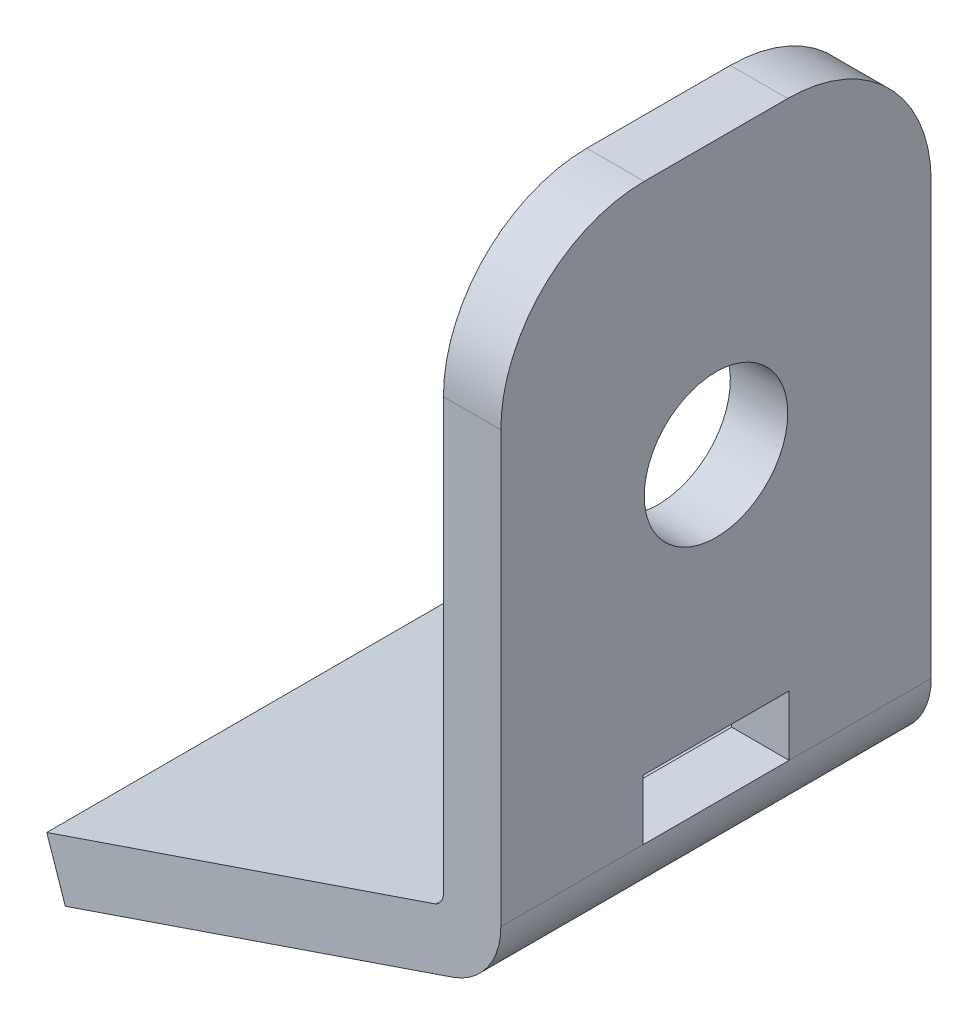
from build123d import *

# Parameters (mm, degrees)
DODANIE_WYCI_GNI_CIE1_DEPTH = 15
SZKIC2_R                    = 2.5
WYTNIJ_WYCI_GNI_CIE2_DEPTH  = 15
SZKIC4_W                    = 5.095426068
SZKIC4_H                    = 2.09659
WYTNIJ_WYCI_GNI_CIE4_DEPTH  = 15
ZAOKR_GLENIE1_R             = 5


with BuildPart() as part:
    # Szkic1 → Dodanie-wyciągnięcie1 (new body)
    with BuildSketch(Plane.XY):
        with BuildLine():
            Line((-21.454955104, -379.577351541), (-23.824138202, -380.384479307))
            Line((-23.824138202, -380.384479307), (-23.175429976, -382.288649415))
            Line((-23.175429976, -382.288649415), (-9.642739559, -377.669332371))
            ThreePointArc((-9.642739559, -377.669332371), (-8.449909807, -376.75404191), (-7.997789918, -375.320100819))
            Line((-7.997789918, -375.320100819), (-8, -355.320100819))
            Line((-8, -355.320100819), (-10, -355.320100819))
            Line((-10, -355.320100819), (-10, -375.320100819))
            ThreePointArc((-10, -375.320100819), (-10.078304277, -375.588750623), (-10.288690869, -375.773254713))
            Line((-10.288690869, -375.773254713), (-21.454955104, -379.577351541))
        make_face()
    extrude(amount=-DODANIE_WYCI_GNI_CIE1_DEPTH)

    # Szkic2 → Wytnij-wyciągnięcie2 (cut)
    with BuildSketch(Plane.ZY.offset(10)):
        with Locations((-7.5, -364.820100819)):
            Circle(SZKIC2_R)
    extrude(amount=-WYTNIJ_WYCI_GNI_CIE2_DEPTH, mode=Mode.SUBTRACT)

    # Szkic4 → Wytnij-wyciągnięcie4 (cut)
    with BuildSketch(Plane.ZY.offset(10)):
        with Locations((-7.500510709, -374.271805819)):
            Rectangle(SZKIC4_W, SZKIC4_H)
    extrude(amount=-WYTNIJ_WYCI_GNI_CIE4_DEPTH, mode=Mode.SUBTRACT)

    # Zaokrąglenie1
    zaokr_glenie1_edges = [part.edges().sort_by_distance(p)[0] for p in [
        (-9, -355.320100819, 0),
        (-9, -355.320100819, -15),
    ]]
    fillet(zaokr_glenie1_edges, radius=ZAOKR_GLENIE1_R)


solid = part.part
